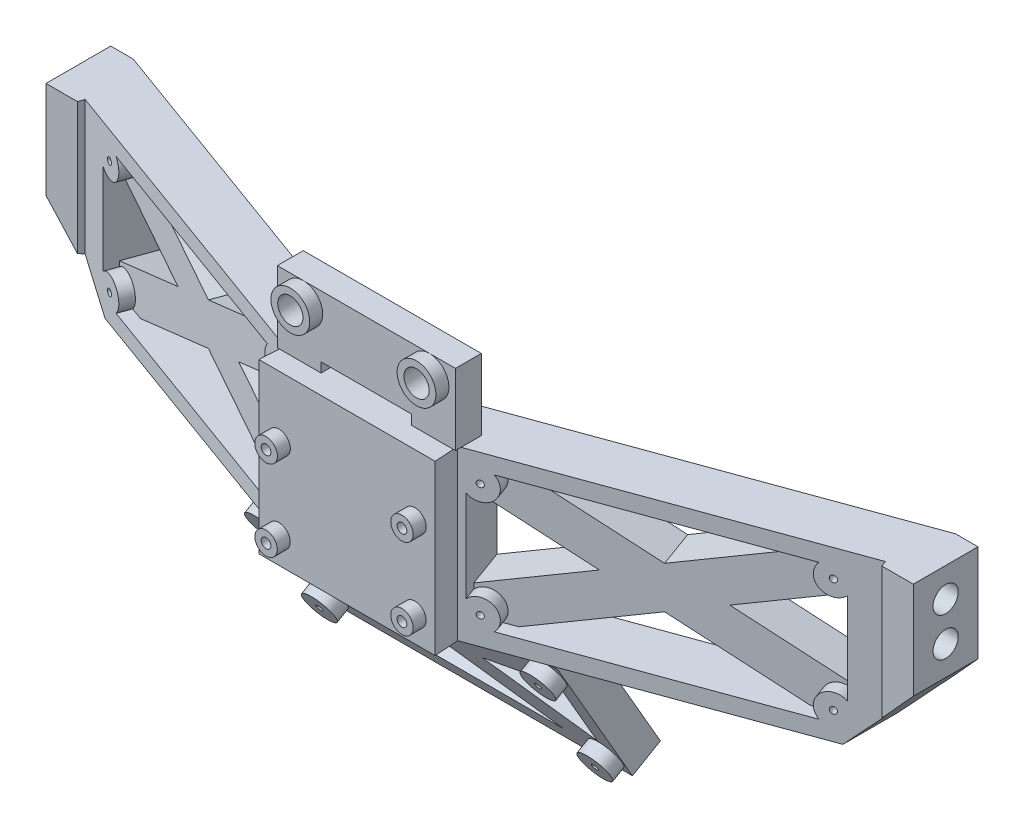
from build123d import *

# Parameters (mm, degrees)
SKETCH1_R                = 6
BOSS_EXTRUDE1_DEPTH      = 10
SKETCH3_R                = 0.75
BOSS_EXTRUDE2_DEPTH      = 15
BOSS_EXTRUDE2_DEPTH_BACK = 25
SKETCH5_W                = 30
SKETCH5_H                = 30.75
CUT_EXTRUDE1_DEPTH       = 2.5
SKETCH14_W               = 50
SKETCH14_H               = 25.4
BOSS_EXTRUDE5_DEPTH      = 38
SKETCH10_W               = 21
SKETCH10_H               = 46
CUT_EXTRUDE3_DEPTH       = 48
SKETCH16_W               = 48
SKETCH16_H               = 7.593294863
BOSS_EXTRUDE6_DEPTH      = 4
SKETCH5_2_W              = 30
SKETCH5_2_H              = 30.75
CUT_EXTRUDE6_DEPTH       = 4
CUT_EXTRUDE6_DEPTH_BACK  = 2.5
CUT_EXTRUDE4_DEPTH       = 40
SKETCH12_R               = 2.421843306
SKETCH12_R_2             = 0.5
BOSS_EXTRUDE4_DEPTH      = 5
SKETCH13_R               = 0.5
CUT_EXTRUDE5_DEPTH       = 15
SKETCH18_W               = 50
SKETCH18_H               = 34.502954744
BOSS_EXTRUDE7_DEPTH      = 2.5
CUT_EXTRUDE10_DEPTH      = 146.821613778
CUT_EXTRUDE12_DEPTH      = 129.953479984
CUT_EXTRUDE17_REACH      = 91.324
CUT_EXTRUDE20_DEPTH      = 116.734016398
SKETCH28_W               = 54.568484475
SKETCH28_H               = 26
CUT_EXTRUDE21_DEPTH      = 102.959878647
BOSS_EXTRUDE9_DEPTH      = 26
CUT_EXTRUDE22_DEPTH      = 100.460512237
BOSS_EXTRUDE11_DEPTH     = 7.992313589
CUT_EXTRUDE23_DEPTH      = 2
BOSS_EXTRUDE12_DEPTH     = 7.992313589
CUT_EXTRUDE24_DEPTH      = 2
SKETCH33_W               = 48
SKETCH33_H               = 23
BOSS_EXTRUDE13_DEPTH     = 5
SKETCH34_R               = 2.5
SKETCH34_R_2             = 0.5
BOSS_EXTRUDE14_DEPTH     = 2
SKETCH35_W               = 28.180148828
SKETCH35_H               = 26
SKETCH35_R               = 1.75
SKETCH35_R_2             = 1.73651938
CUT_EXTRUDE25_DEPTH      = 5
CUT_EXTRUDE27_DEPTH      = 96.41448763
SKETCH37_R               = 1.73651938
SKETCH37_R_2             = 0.75
SKETCH37_R_3             = 1.75
CUT_EXTRUDE28_DEPTH      = 3
BOSS_EXTRUDE15_REACH     = 115.866
BOSS_EXTRUDE16_DEPTH     = 1.474239
CUT_EXTRUDE29_DEPTH      = 86.045598256
CUT_EXTRUDE32_DEPTH      = 100.770044675
SKETCH45_W               = 0.142393119
SKETCH45_H               = 10
BOSS_EXTRUDE17_DEPTH     = 26
CUT_EXTRUDE37_DEPTH      = 100.356995224
BOSS_EXTRUDE18_START     = -5
BOSS_EXTRUDE18_DEPTH     = 4
BOSS_EXTRUDE19_START     = -5
SKETCH50_R               = 3
SKETCH50_R_2             = 1.95
BOSS_EXTRUDE19_DEPTH     = 2
SKETCH51_R               = 1.95
CUT_EXTRUDE39_DEPTH      = 109.019963433
SKETCH52_R               = 0.75
CUT_EXTRUDE40_DEPTH      = 109.019963433
SKETCH55_R               = 1.95
CUT_EXTRUDE42_DEPTH      = 10
CUT_EXTRUDE43_START      = -134
SKETCH55_2_R             = 1.95
CUT_EXTRUDE43_DEPTH      = 10
SKETCH56_W               = 27.512438804
SKETCH56_H               = 26
SKETCH56_R               = 1.73651938
SKETCH56_R_2             = 1.75
CUT_EXTRUDE44_DEPTH      = 2
SKETCH57_R               = 1.73651938
SKETCH57_R_2             = 1.75
CUT_EXTRUDE45_DEPTH      = 2
SKETCH58_W               = 27.512438804
SKETCH58_H               = 2.5
CUT_EXTRUDE46_DEPTH      = 107.622288946


with BuildPart() as part:
    # Sketch1 → Boss-Extrude1 (new body)
    with BuildSketch(Plane.XY):
        Polygon((-55, 98), (55, 98), (80, 78), (77.932657225, 6.656289752), (70, 0), (-70, 0), (-77.932657225, 6.656289752), (-80, 78), align=None)
        with Locations((-70, 28)):
            Circle(SKETCH1_R, mode=Mode.SUBTRACT)
        with Locations((70, 28)):
            Circle(SKETCH1_R, mode=Mode.SUBTRACT)
        with BuildLine():
            Line((-67.831737509, 72.367111823), (-50.790627288, 86))
            Line((-50.790627288, 86), (50.790627288, 86))
            Line((50.790627288, 86), (67.831737509, 72.367111823))
            Line((67.831737509, 72.367111823), (66.741852409, 34.755329324))
            ThreePointArc((66.741852409, 34.755329324), (62.503146817, 28.217238005), (66.356146477, 21.444671518))
            Line((66.356146477, 21.444671518), (66.09368314, 12.387098435))
            Line((66.09368314, 12.387098435), (65.632357189, 12))
            Line((65.632357189, 12), (-65.632357189, 12))
            Line((-65.632357189, 12), (-66.09368314, 12.387098435))
            Line((-66.09368314, 12.387098435), (-66.356146477, 21.444671518))
            ThreePointArc((-66.356146477, 21.444671518), (-62.503146817, 28.217238005), (-66.741852409, 34.755329324))
            Line((-66.741852409, 34.755329324), (-67.831737509, 72.367111823))
        make_face(mode=Mode.SUBTRACT)
    extrude(amount=BOSS_EXTRUDE1_DEPTH)



with BuildPart() as body_2:
    # Sketch3 → Boss-Extrude2 (new, two sides)
    with BuildSketch(Plane(origin=(0, 0, 0), x_dir=(-1, 0, 0), z_dir=(0, 0, -1))) as boss_extrude2_sk:
        Polygon((-13.5, 64.75), (-67.611014743, 64.75), (-66.857606881, 38.75), (-13.5, 38.75), (13.5, 38.75), (66.857606881, 38.75), (67.611014743, 64.75), (13.5, 64.75), align=None)
        with Locations((-10.5, 55.25)):
            Circle(SKETCH3_R, mode=Mode.SUBTRACT)
        with Locations((10.5, 55.25)):
            Circle(SKETCH3_R, mode=Mode.SUBTRACT)
        with Locations((10.5, 42.75)):
            Circle(SKETCH3_R, mode=Mode.SUBTRACT)
        with Locations((-10.5, 42.75)):
            Circle(SKETCH3_R, mode=Mode.SUBTRACT)
    extrude(amount=BOSS_EXTRUDE2_DEPTH)
    extrude(boss_extrude2_sk.sketch, amount=-BOSS_EXTRUDE2_DEPTH_BACK)

    # Sketch5 → Cut-Extrude1 (cut)
    with BuildSketch(Plane.XY.offset(25)):
        with Locations((0, 49.375)):
            Rectangle(SKETCH5_W, SKETCH5_H)
    extrude(amount=-CUT_EXTRUDE1_DEPTH, mode=Mode.SUBTRACT)


with BuildPart() as part_1:
    add(part.part)

    add(body_2.part)  # Boss-Extrude5 merges body 2
    # Sketch14 → Boss-Extrude5 (add)
    with BuildSketch(Plane(origin=(0, -1.317309472, 2.281646934), x_dir=(-1, 0, 0), z_dir=(0, -0.499999999999998, 0.8660254037844398))):
        with Locations((0, -26.058484397)):
            Rectangle(SKETCH14_W, SKETCH14_H)
    extrude(amount=-BOSS_EXTRUDE5_DEPTH)

    # Sketch10 → Cut-Extrude3 (cut)
    with BuildSketch(Plane(origin=(20.050116097, 0, 55.087241235), x_dir=(0, 1, 0), z_dir=(0.34202014332566943, 0, 0.9396926207859081))):
        with Locations((51.75, -32.544885729)):
            Rectangle(SKETCH10_W, SKETCH10_H)
    cut_extrude3 = extrude(amount=-CUT_EXTRUDE3_DEPTH, mode=Mode.SUBTRACT)

    # Sketch16 → Boss-Extrude6 (add)
    with BuildSketch(Plane(origin=(0, 33.5658321, 19.379242198), x_dir=(1, 0, 0), z_dir=(0, 0.8660254037844397, 0.499999999999998))):
        with Locations((-1, 1.162028489)):
            Rectangle(SKETCH16_W, SKETCH16_H)
    extrude(amount=BOSS_EXTRUDE6_DEPTH)

    # Sketch5_2 → Cut-Extrude6 (cut, two sides)
    with BuildSketch(Plane.XY.offset(25)) as cut_extrude6_sk:
        with Locations((0, 49.375)):
            Rectangle(SKETCH5_2_W, SKETCH5_2_H)
    extrude(amount=CUT_EXTRUDE6_DEPTH, mode=Mode.SUBTRACT)
    extrude(cut_extrude6_sk.sketch, amount=-CUT_EXTRUDE6_DEPTH_BACK, mode=Mode.SUBTRACT)

    # Mirror1: Cut-Extrude3 across plane
    add(cut_extrude3.mirror(Plane(origin=(0, 0, 0), x_dir=(0, 0, 1), z_dir=(1, 0, 0))), mode=Mode.SUBTRACT)

    # Sketch11 → Cut-Extrude4 (cut)
    with BuildSketch(Plane(origin=(0, 64.75, 0), x_dir=(1, 0, 0), z_dir=(0, 1, 0))):
        Polygon((-67.611014743, -10), (-15, -25), (15, -25), (67.611014743, -10), (67.611014743, -47.097490731), (-67.611014743, -47.097490731), align=None)
    extrude(amount=-CUT_EXTRUDE4_DEPTH, mode=Mode.SUBTRACT)

    # Sketch12 → Boss-Extrude4 (add)
    with BuildSketch(Plane(origin=(3.633149218, 0, 9.981995437), x_dir=(0.9396926207859082, 0, -0.34202014332566955), z_dir=(0.34202014332566955, 0, 0.9396926207859082))):
        with Locations((11.259885729, 60.54)):
            Circle(SKETCH12_R)
        with Locations((11.259885729, 60.54)):
            Circle(SKETCH12_R_2, mode=Mode.SUBTRACT)
        with Locations((53.829885729, 60.54)):
            Circle(SKETCH12_R)
        with Locations((53.829885729, 60.54)):
            Circle(SKETCH12_R_2, mode=Mode.SUBTRACT)
        with Locations((53.829885729, 42.96)):
            Circle(SKETCH12_R)
        with Locations((53.829885729, 42.96)):
            Circle(SKETCH12_R_2, mode=Mode.SUBTRACT)
        with Locations((11.259885729, 42.96)):
            Circle(SKETCH12_R)
        with Locations((11.259885729, 42.96)):
            Circle(SKETCH12_R_2, mode=Mode.SUBTRACT)
    boss_extrude4 = extrude(amount=BOSS_EXTRUDE4_DEPTH)

    # Sketch13 → Cut-Extrude5 (cut)
    with BuildSketch(Plane(origin=(3.633149218, 0, 9.981995437), x_dir=(0.9396926207859082, 0, -0.3420201433256695), z_dir=(0.3420201433256695, 0, 0.9396926207859082))):
        with Locations((53.829885729, 60.54)):
            Circle(SKETCH13_R)
        with Locations((53.829885729, 42.96)):
            Circle(SKETCH13_R)
        with Locations((11.259885729, 42.96)):
            Circle(SKETCH13_R)
        with Locations((11.259885729, 60.54)):
            Circle(SKETCH13_R)
    cut_extrude5 = extrude(amount=-CUT_EXTRUDE5_DEPTH, mode=Mode.SUBTRACT)

    # Mirror2: Boss-Extrude4, Cut-Extrude5 across plane
    add(boss_extrude4.mirror(Plane(origin=(0, 0, 0), x_dir=(0, 0, 1), z_dir=(1, 0, 0))))
    add(cut_extrude5.mirror(Plane(origin=(0, 0, 0), x_dir=(0, 0, 1), z_dir=(1, 0, 0))), mode=Mode.SUBTRACT)

    # Sketch18 → Boss-Extrude7 (add)
    with BuildSketch(Plane(origin=(0, 11.568786844, 6.679242198), x_dir=(1, 0, 0), z_dir=(0, -0.8660254037844397, -0.499999999999998))):
        with Locations((0, -18.113903685)):
            Rectangle(SKETCH18_W, SKETCH18_H)
    extrude(amount=BOSS_EXTRUDE7_DEPTH)

    # Sketch20 → Cut-Extrude10 (cut, through all)
    with BuildSketch(Plane(origin=(25, 0, 0), x_dir=(0, 0, -1), z_dir=(1, 0, 0))):
        Polygon((15, 44.75), (15, 38.75), (8.051233494, 17.186679604), (32.373818215, 22.723551455), (24.867864478, 46.825237766), align=None)
    extrude(amount=-CUT_EXTRUDE10_DEPTH, mode=Mode.SUBTRACT)

    # Sketch21 → Cut-Extrude12 (cut, through all)
    with BuildSketch(Plane.XY.offset(10)):
        Polygon((80, 78), (55, 98), (-55, 98), (-80, 78), (-77.932657225, 6.656289752), (-70, 0), (70, 0), (77.932657225, 6.656289752), align=None)
        with BuildLine():
            Line((-67.611014743, 64.75), (-66.857606881, 38.75))
            Line((-66.857606881, 38.75), (-66.741852409, 34.755329324))
            ThreePointArc((-66.741852409, 34.755329324), (-62.503146817, 28.217238005), (-66.356146477, 21.444671518))
            Line((-66.356146477, 21.444671518), (-66.09368314, 12.387098435))
            Line((-66.09368314, 12.387098435), (-65.632357189, 12))
            Line((-65.632357189, 12), (65.632357189, 12))
            Line((65.632357189, 12), (66.09368314, 12.387098435))
            Line((66.09368314, 12.387098435), (66.356146477, 21.444671518))
            ThreePointArc((66.356146477, 21.444671518), (62.503146817, 28.217238005), (66.741852409, 34.755329324))
            Line((66.741852409, 34.755329324), (66.857606881, 38.75))
            Line((66.857606881, 38.75), (67.611014743, 64.75))
            Line((67.611014743, 64.75), (67.831737509, 72.367111823))
            Line((67.831737509, 72.367111823), (50.790627288, 86))
            Line((50.790627288, 86), (-50.790627288, 86))
            Line((-50.790627288, 86), (-67.831737509, 72.367111823))
            Line((-67.831737509, 72.367111823), (-67.611014743, 64.75))
        make_face(mode=Mode.SUBTRACT)
    extrude(amount=-CUT_EXTRUDE12_DEPTH, mode=Mode.SUBTRACT)

    # Sketch26 → Cut-Extrude17 (cut, up to next)
    with BuildSketch(Plane(origin=(0, 64.75, 0), x_dir=(1, 0, 0), z_dir=(0, 1, 0)), mode=Mode.PRIVATE) as cut_extrude17_sk1:
        Polygon((0, -8.12), (-103.081644476, 29.398650288), (100.191184864, 28.346609026), align=None)
    cut_extrude17_tool1 = extrude(cut_extrude17_sk1.sketch, amount=-CUT_EXTRUDE17_REACH, mode=Mode.PRIVATE) & part_1.part
    add(cut_extrude17_tool1.solids().sort_by_distance((-0.963487, 64.75, -16.541753))[0], mode=Mode.SUBTRACT)

    # Sketch27 → Cut-Extrude20 (cut, through all)
    with BuildSketch(Plane.ZY.offset(25)):
        Polygon((-0.979255857, 38.75), (29.245394975, 38.75), (32.788291765, 8.744578546), (-21.074810998, 9.132082883), align=None)
    extrude(amount=-CUT_EXTRUDE20_DEPTH, mode=Mode.SUBTRACT)

    # Sketch28 → Cut-Extrude21 (cut, through all)
    with BuildSketch(Plane(origin=(-5.343249934, 0, 14.680458541), x_dir=(0.9396926207859081, 0, 0.34202014332566955), z_dir=(-0.34202014332566955, 0, 0.9396926207859082))):
        with Locations((-32.829127967, 51.75)):
            Rectangle(SKETCH28_W, SKETCH28_H)
    cut_extrude21 = extrude(amount=CUT_EXTRUDE21_DEPTH, mode=Mode.SUBTRACT)

    # Mirror3: Cut-Extrude21 across plane
    add(cut_extrude21.mirror(Plane(origin=(0, 0, 0), x_dir=(0, 0, 1), z_dir=(1, 0, 0))), mode=Mode.SUBTRACT)

    # Sketch29 → Boss-Extrude9 (add)
    with BuildSketch(Plane(origin=(0, 64.75, 0), x_dir=(1, 0, 0), z_dir=(0, 1, 0))):
        Polygon((-14.090074414, -22.5), (-13.372815999, -11.7579355), (-10.553738137, -12.78399593), align=None)
        Polygon((13.372815999, -11.7579355), (10.553738137, -12.78399593), (14.090074414, -22.5), align=None)
    extrude(amount=-BOSS_EXTRUDE9_DEPTH)

    # Sketch31 → Cut-Extrude22 (cut, through all)
    with BuildSketch(Plane(origin=(3.633149218, 0, 9.981995437), x_dir=(0.9396926207859082, 0, -0.3420201433256695), z_dir=(0.3420201433256695, 0, 0.9396926207859082))):
        with BuildLine():
            Line((9.544885729, 58.83), (9.544885729, 44.67))
            ThreePointArc((9.544885729, 44.67), (12.969885729, 44.675), (12.974885729, 41.25))
            Line((12.974885729, 41.25), (52.114885729, 41.25))
            ThreePointArc((52.114885729, 41.25), (52.119885729, 44.675), (55.544885729, 44.67))
            Line((55.544885729, 44.67), (55.544885729, 58.83))
            ThreePointArc((55.544885729, 58.83), (52.119885729, 58.825), (52.114885729, 62.25))
            Line((52.114885729, 62.25), (12.974885729, 62.25))
            ThreePointArc((12.974885729, 62.25), (12.969885729, 58.825), (9.544885729, 58.83))
        make_face()
    cut_extrude22 = extrude(amount=-CUT_EXTRUDE22_DEPTH, mode=Mode.SUBTRACT)

    # Mirror4: Cut-Extrude22 across plane
    add(cut_extrude22.mirror(Plane(origin=(0, 0, 0), x_dir=(0, 0, 1), z_dir=(1, 0, 0))), mode=Mode.SUBTRACT)

    # Sketch30 → Boss-Extrude11 (add)
    with BuildSketch(Plane(origin=(-5.343249934, 0, 14.680458541), x_dir=(0.9396926207859081, 0, 0.34202014332566955), z_dir=(-0.34202014332566955, 0, 0.9396926207859082))):
        with BuildLine():
            Line((-55.544885729, 58.002491012), (-40.404468073, 51.75))
            Line((-40.404468073, 51.75), (-55.544885729, 45.497508988))
            Line((-55.544885729, 45.497508988), (-55.544885729, 44.67))
            ThreePointArc((-55.544885729, 44.67), (-52.119885729, 44.675), (-52.114885729, 41.25))
            Line((-52.114885729, 41.25), (-50.111071302, 41.25))
            Line((-50.111071302, 41.25), (-32.544885729, 48.504252816))
            Line((-32.544885729, 48.504252816), (-14.978700155, 41.25))
            Line((-14.978700155, 41.25), (-12.974885729, 41.25))
            ThreePointArc((-12.974885729, 41.25), (-12.969885729, 44.675), (-9.544885729, 44.67))
            Line((-9.544885729, 44.67), (-9.544885729, 45.497508988))
            Line((-9.544885729, 45.497508988), (-24.685303384, 51.75))
            Line((-24.685303384, 51.75), (-9.544885729, 58.002491012))
            Line((-9.544885729, 58.002491012), (-9.544885729, 58.83))
            ThreePointArc((-9.544885729, 58.83), (-12.969885729, 58.825), (-12.974885729, 62.25))
            Line((-12.974885729, 62.25), (-14.978700155, 62.25))
            Line((-14.978700155, 62.25), (-32.544885729, 54.995747184))
            Line((-32.544885729, 54.995747184), (-50.111071302, 62.25))
            Line((-50.111071302, 62.25), (-52.114885729, 62.25))
            ThreePointArc((-52.114885729, 62.25), (-52.119885729, 58.825), (-55.544885729, 58.83))
            Line((-55.544885729, 58.83), (-55.544885729, 58.002491012))
        make_face()
    extrude(amount=-BOSS_EXTRUDE11_DEPTH)

    # Sketch30_2 → Cut-Extrude23 (cut)
    with BuildSketch(Plane(origin=(-5.343249934, 0, 14.680458541), x_dir=(0.9396926207859081, 0, 0.34202014332566955), z_dir=(-0.34202014332566955, 0, 0.9396926207859082))):
        with BuildLine():
            Line((-55.544885729, 58.002491012), (-40.404468073, 51.75))
            Line((-40.404468073, 51.75), (-55.544885729, 45.497508988))
            Line((-55.544885729, 45.497508988), (-55.544885729, 44.67))
            ThreePointArc((-55.544885729, 44.67), (-52.119885729, 44.675), (-52.114885729, 41.25))
            Line((-52.114885729, 41.25), (-50.111071302, 41.25))
            Line((-50.111071302, 41.25), (-32.544885729, 48.504252816))
            Line((-32.544885729, 48.504252816), (-14.978700155, 41.25))
            Line((-14.978700155, 41.25), (-12.974885729, 41.25))
            ThreePointArc((-12.974885729, 41.25), (-12.969885729, 44.675), (-9.544885729, 44.67))
            Line((-9.544885729, 44.67), (-9.544885729, 45.497508988))
            Line((-9.544885729, 45.497508988), (-24.685303384, 51.75))
            Line((-24.685303384, 51.75), (-9.544885729, 58.002491012))
            Line((-9.544885729, 58.002491012), (-9.544885729, 58.83))
            ThreePointArc((-9.544885729, 58.83), (-12.969885729, 58.825), (-12.974885729, 62.25))
            Line((-12.974885729, 62.25), (-14.978700155, 62.25))
            Line((-14.978700155, 62.25), (-32.544885729, 54.995747184))
            Line((-32.544885729, 54.995747184), (-50.111071302, 62.25))
            Line((-50.111071302, 62.25), (-52.114885729, 62.25))
            ThreePointArc((-52.114885729, 62.25), (-52.119885729, 58.825), (-55.544885729, 58.83))
            Line((-55.544885729, 58.83), (-55.544885729, 58.002491012))
        make_face()
    extrude(amount=-CUT_EXTRUDE23_DEPTH, mode=Mode.SUBTRACT)

    # Sketch32 → Boss-Extrude12 (add)
    with BuildSketch(Plane(origin=(5.343249934, 0, 14.680458541), x_dir=(0.9396926207859081, 0, -0.34202014332566955), z_dir=(0.34202014332566955, 0, 0.9396926207859082))):
        with BuildLine():
            Line((32.544885729, 54.995747184), (14.978700155, 62.25))
            Line((14.978700155, 62.25), (12.974885729, 62.25))
            ThreePointArc((12.974885729, 62.25), (12.969885729, 58.825), (9.544885729, 58.83))
            Line((9.544885729, 58.83), (9.544885729, 58.002491012))
            Line((9.544885729, 58.002491012), (24.685303384, 51.75))
            Line((24.685303384, 51.75), (32.544885729, 54.995747184))
        make_face()
        with BuildLine():
            Line((50.111071302, 62.25), (32.544885729, 54.995747184))
            Line((32.544885729, 54.995747184), (40.404468073, 51.75))
            Line((40.404468073, 51.75), (55.544885729, 58.002491012))
            Line((55.544885729, 58.002491012), (55.544885729, 58.83))
            ThreePointArc((55.544885729, 58.83), (52.119885729, 58.825), (52.114885729, 62.25))
            Line((52.114885729, 62.25), (50.111071302, 62.25))
        make_face()
        Polygon((40.404468073, 51.75), (32.544885729, 54.995747184), (24.685303384, 51.75), (32.544885729, 48.504252816), align=None)
        with BuildLine():
            Line((32.544885729, 48.504252816), (24.685303384, 51.75))
            Line((24.685303384, 51.75), (9.544885729, 45.497508988))
            Line((9.544885729, 45.497508988), (9.544885729, 44.67))
            ThreePointArc((9.544885729, 44.67), (12.969885729, 44.675), (12.974885729, 41.25))
            Line((12.974885729, 41.25), (14.978700155, 41.25))
            Line((14.978700155, 41.25), (32.544885729, 48.504252816))
        make_face()
        with BuildLine():
            Line((55.544885729, 45.497508988), (40.404468073, 51.75))
            Line((40.404468073, 51.75), (32.544885729, 48.504252816))
            Line((32.544885729, 48.504252816), (50.111071302, 41.25))
            Line((50.111071302, 41.25), (52.114885729, 41.25))
            ThreePointArc((52.114885729, 41.25), (52.119885729, 44.675), (55.544885729, 44.67))
            Line((55.544885729, 44.67), (55.544885729, 45.497508988))
        make_face()
    extrude(amount=-BOSS_EXTRUDE12_DEPTH)

    # Sketch32_4 → Cut-Extrude24 (cut)
    with BuildSketch(Plane(origin=(5.343249934, 0, 14.680458541), x_dir=(0.9396926207859081, 0, -0.34202014332566955), z_dir=(0.34202014332566955, 0, 0.9396926207859082))):
        with BuildLine():
            Line((32.544885729, 54.995747184), (14.978700155, 62.25))
            Line((14.978700155, 62.25), (12.974885729, 62.25))
            ThreePointArc((12.974885729, 62.25), (12.969885729, 58.825), (9.544885729, 58.83))
            Line((9.544885729, 58.83), (9.544885729, 58.002491012))
            Line((9.544885729, 58.002491012), (24.685303384, 51.75))
            Line((24.685303384, 51.75), (32.544885729, 54.995747184))
        make_face()
        Polygon((40.404468073, 51.75), (32.544885729, 54.995747184), (24.685303384, 51.75), (32.544885729, 48.504252816), align=None)
        with BuildLine():
            Line((50.111071302, 62.25), (32.544885729, 54.995747184))
            Line((32.544885729, 54.995747184), (40.404468073, 51.75))
            Line((40.404468073, 51.75), (55.544885729, 58.002491012))
            Line((55.544885729, 58.002491012), (55.544885729, 58.83))
            ThreePointArc((55.544885729, 58.83), (52.119885729, 58.825), (52.114885729, 62.25))
            Line((52.114885729, 62.25), (50.111071302, 62.25))
        make_face()
        with BuildLine():
            Line((55.544885729, 45.497508988), (40.404468073, 51.75))
            Line((40.404468073, 51.75), (32.544885729, 48.504252816))
            Line((32.544885729, 48.504252816), (50.111071302, 41.25))
            Line((50.111071302, 41.25), (52.114885729, 41.25))
            ThreePointArc((52.114885729, 41.25), (52.119885729, 44.675), (55.544885729, 44.67))
            Line((55.544885729, 44.67), (55.544885729, 45.497508988))
        make_face()
        with BuildLine():
            Line((32.544885729, 48.504252816), (24.685303384, 51.75))
            Line((24.685303384, 51.75), (9.544885729, 45.497508988))
            Line((9.544885729, 45.497508988), (9.544885729, 44.67))
            ThreePointArc((9.544885729, 44.67), (12.969885729, 44.675), (12.974885729, 41.25))
            Line((12.974885729, 41.25), (14.978700155, 41.25))
            Line((14.978700155, 41.25), (32.544885729, 48.504252816))
        make_face()
    extrude(amount=-CUT_EXTRUDE24_DEPTH, mode=Mode.SUBTRACT)

    # Sketch33 → Boss-Extrude13 (add)
    with BuildSketch(Plane(origin=(0, 8.944714207, -15.492699466), x_dir=(1, 0, 0), z_dir=(0, -0.5000000000000101, 0.8660254037844328))):
        with Locations((0, 24.618484397)):
            Rectangle(SKETCH33_W, SKETCH33_H)
    extrude(amount=BOSS_EXTRUDE13_DEPTH)

    # Sketch34 → Boss-Extrude14 (add)
    with BuildSketch(Plane(origin=(0, 6.444714207, -11.162572448), x_dir=(1, 0, 0), z_dir=(0, -0.5000000000000102, 0.8660254037844327))):
        with Locations(Location((-21.285, 33.408484397, 0), (0, 0, 90))):
            Circle(SKETCH34_R)
        with Locations(Location((-21.285, 33.408484397, 0), (0, 0, 270))):
            Circle(SKETCH34_R_2, mode=Mode.SUBTRACT)
        with Locations(Location((-21.285, 15.828484397, 0), (0, 0, 90))):
            Circle(SKETCH34_R)
        with Locations(Location((-21.285, 15.828484397, 0), (0, 0, 270))):
            Circle(SKETCH34_R_2, mode=Mode.SUBTRACT)
        with Locations(Location((21.285, 15.828484397, 0), (0, 0, 90))):
            Circle(SKETCH34_R)
        with Locations(Location((21.285, 15.828484397, 0), (0, 0, 270))):
            Circle(SKETCH34_R_2, mode=Mode.SUBTRACT)
        with Locations(Location((21.285, 33.408484397, 0), (0, 0, 90))):
            Circle(SKETCH34_R)
        with Locations(Location((21.285, 33.408484397, 0), (0, 0, 270))):
            Circle(SKETCH34_R_2, mode=Mode.SUBTRACT)
    extrude(amount=BOSS_EXTRUDE14_DEPTH)

    # Sketch35 → Cut-Extrude25 (cut)
    with BuildSketch(Plane.XY.offset(22.5)):
        with Locations((0, 51.75)):
            Rectangle(SKETCH35_W, SKETCH35_H)
        with Locations((-10.5, 55.25)):
            Circle(SKETCH35_R, mode=Mode.SUBTRACT)
        with Locations((10.5, 55.25)):
            Circle(SKETCH35_R_2, mode=Mode.SUBTRACT)
        with Locations((10.5, 42.75)):
            Circle(SKETCH35_R_2, mode=Mode.SUBTRACT)
        with Locations((-10.5, 42.75)):
            Circle(SKETCH35_R_2, mode=Mode.SUBTRACT)
    extrude(amount=-CUT_EXTRUDE25_DEPTH, mode=Mode.SUBTRACT)

    # Sketch36 → Cut-Extrude27 (cut, through all)
    with BuildSketch(Plane(origin=(0, 6.444714207, -11.162572448), x_dir=(1, 0, 0), z_dir=(0, -0.5000000000000103, 0.8660254037844328))):
        Polygon((-14.735348046, 33.408484397), (0, 27.323273717), (14.735348046, 33.408484397), align=None)
        Polygon((14.735348046, 15.828484397), (0, 21.913695077), (-14.735348046, 15.828484397), align=None)
        Polygon((-21.285, 18.533273717), (-6.549651954, 24.618484397), (-21.285, 30.703695077), align=None)
        Polygon((21.285, 30.703695077), (6.549651954, 24.618484397), (21.285, 18.533273717), align=None)
    extrude(amount=-CUT_EXTRUDE27_DEPTH, mode=Mode.SUBTRACT)

    # Sketch37 → Cut-Extrude28 (cut)
    with BuildSketch(Plane.XY.offset(22.5)):
        with Locations((10.5, 42.75)):
            Circle(SKETCH37_R)
        with Locations(Location((10.5, 42.75, 0), (0, 0, 230.377503167))):
            Circle(SKETCH37_R_2, mode=Mode.SUBTRACT)
        with Locations((10.5, 55.25)):
            Circle(SKETCH37_R)
        with Locations((10.5, 55.25)):
            Circle(SKETCH37_R_2, mode=Mode.SUBTRACT)
        with Locations((-10.5, 42.75)):
            Circle(SKETCH37_R)
        with Locations(Location((-10.5, 42.75, 0), (0, 0, 206.642765316))):
            Circle(SKETCH37_R_2, mode=Mode.SUBTRACT)
        with Locations((-10.5, 55.25)):
            Circle(SKETCH37_R_3)
        with Locations(Location((-10.5, 55.25, 0), (0, 0, 180))):
            Circle(SKETCH37_R_2, mode=Mode.SUBTRACT)
    extrude(amount=-CUT_EXTRUDE28_DEPTH, mode=Mode.SUBTRACT)

    # Boss-Extrude15: up to this face of the body (flat: up to its plane)
    boss_extrude15_end = Plane(part_1.part.faces().sort_by_distance((24, 28.786799743, -1.111031094))[0])
    # Sketch38 → Boss-Extrude15 (add, up to the picked face)
    with BuildSketch(Plane.ZY.offset(24), mode=Mode.PRIVATE) as boss_extrude15_sk1:
        Polygon((5.12, 38.75), (6.896669751, 37.724239241), (7.930028914, 38.75), align=None)
    boss_extrude15_tool1 = split(extrude(boss_extrude15_sk1.sketch, amount=-BOSS_EXTRUDE15_REACH, mode=Mode.PRIVATE), bisect_by=boss_extrude15_end, keep=Keep.BOTH, mode=Mode.PRIVATE)
    add(boss_extrude15_tool1.solids().sort_by(Axis((-24, 38.40808, 6.6489), (1, 0, 0)))[0])

    # Sketch39 → Boss-Extrude16 (add)
    with BuildSketch(Plane(origin=(0, 38.75, 0), x_dir=(1, 0, 0), z_dir=(0, 1, 0))):
        Polygon((0, -8.12), (-15.257998444, -2.566542732), (15.257998444, -2.566542732), align=None)
    extrude(amount=BOSS_EXTRUDE16_DEPTH)

    # Sketch40 → Cut-Extrude29 (cut, through all)
    with BuildSketch(Plane(origin=(0, 64.75, 0), x_dir=(1, 0, 0), z_dir=(0, 1, 0))):
        Polygon((-67.611014743, -10), (-67.611014743, 5), (-62.151461229, 5), align=None)
        Polygon((67.611014743, -10), (67.611014743, 5), (62.151461229, 5), align=None)
    extrude(amount=-CUT_EXTRUDE29_DEPTH, mode=Mode.SUBTRACT)

    # Sketch43 → Cut-Extrude32 (cut, through all)
    with BuildSketch(Plane(origin=(0, 0, -15), x_dir=(-1, 0, 0), z_dir=(0, 0, -1))):
        Polygon((-66.857606881, 38.75), (-66.857606881, 64.75), (-67.611014743, 64.75), align=None)
        Polygon((66.857606881, 38.75), (66.857606881, 64.75), (67.611014743, 64.75), align=None)
    extrude(amount=-CUT_EXTRUDE32_DEPTH, mode=Mode.SUBTRACT)

    # Sketch45 → Boss-Extrude17 (add)
    with BuildSketch(Plane(origin=(0, 64.75, 0), x_dir=(1, 0, 0), z_dir=(0, 1, 0))):
        with Locations((-66.928803441, 10)):
            Rectangle(SKETCH45_W, SKETCH45_H)
        with Locations((66.928803441, 10)):
            Rectangle(SKETCH45_W, SKETCH45_H)
    extrude(amount=-BOSS_EXTRUDE17_DEPTH)

    # Sketch47 → Cut-Extrude37 (cut, through all)
    with BuildSketch(Plane(origin=(0, 0, -15), x_dir=(-1, 0, 0), z_dir=(0, 0, -1))):
        Polygon((57, 38.75), (67, 49.75), (67, 38.75), align=None)
        Polygon((-67, 38.75), (-57, 38.75), (-67, 49.75), align=None)
    extrude(amount=-CUT_EXTRUDE37_DEPTH, mode=Mode.SUBTRACT)

    # Sketch48 → Boss-Extrude18 (add)
    with BuildSketch(Plane.XY.offset(17.5).offset(BOSS_EXTRUDE18_START)):
        Polygon((-13.756219402, 64.75), (-7, 64.75), (-7, 66.25), (7, 66.25), (7, 64.75), (13.756219402, 64.75), (13.756219402, 78.25), (-13.756219402, 78.25), align=None)
    extrude(amount=-BOSS_EXTRUDE18_DEPTH)

    # Sketch50 → Boss-Extrude19 (add)
    with BuildSketch(Plane.XY.offset(17.5).offset(BOSS_EXTRUDE19_START)):
        with Locations(Location((9.75, 72.75, 0), (0, 0, 180))):
            Circle(SKETCH50_R)
        with Locations(Location((9.75, 72.75, 0), (0, 0, 180))):
            Circle(SKETCH50_R_2, mode=Mode.SUBTRACT)
        with Locations(Location((-9.75, 72.75, 0), (0, 0, 180))):
            Circle(SKETCH50_R)
        with Locations(Location((-9.75, 72.75, 0), (0, 0, 180))):
            Circle(SKETCH50_R_2, mode=Mode.SUBTRACT)
    extrude(amount=BOSS_EXTRUDE19_DEPTH)

    # Sketch51 → Cut-Extrude39 (cut, through all)
    with BuildSketch(Plane.XY.offset(17.5)):
        with Locations(Location((9.75, 72.75, 0), (0, 0, 180))):
            Circle(SKETCH51_R)
        with Locations(Location((-9.75, 72.75, 0), (0, 0, 180))):
            Circle(SKETCH51_R)
    extrude(amount=-CUT_EXTRUDE39_DEPTH, mode=Mode.SUBTRACT)

    # Sketch52 → Cut-Extrude40 (cut, through all)
    with BuildSketch(Plane.XY.offset(17.5)):
        with Locations(Location((-10.5, 55.25, 0), (0, 0, 180))):
            Circle(SKETCH52_R)
        with Locations((10.5, 55.25)):
            Circle(SKETCH52_R)
        with Locations((10.5, 42.75)):
            Circle(SKETCH52_R)
        with Locations(Location((-10.5, 42.75, 0), (0, 0, 180))):
            Circle(SKETCH52_R)
    extrude(amount=-CUT_EXTRUDE40_DEPTH, mode=Mode.SUBTRACT)

    # Sketch55 → Cut-Extrude42 (cut)
    with BuildSketch(Plane.ZY.offset(67)):
        with Locations((-10, 60.25)):
            Circle(SKETCH55_R)
        with Locations((-10, 54.25)):
            Circle(SKETCH55_R)
    extrude(amount=-CUT_EXTRUDE42_DEPTH, mode=Mode.SUBTRACT)

    # Sketch55_2 → Cut-Extrude43 (cut)
    with BuildSketch(Plane.ZY.offset(67).offset(CUT_EXTRUDE43_START)):
        with Locations((-10, 60.25)):
            Circle(SKETCH55_2_R)
        with Locations((-10, 54.25)):
            Circle(SKETCH55_2_R)
    extrude(amount=CUT_EXTRUDE43_DEPTH, mode=Mode.SUBTRACT)

    # Sketch56 → Cut-Extrude44 (cut)
    with BuildSketch(Plane.XY.offset(17.5)):
        with Locations((0, 51.75)):
            Rectangle(SKETCH56_W, SKETCH56_H)
        with Locations((-10.5, 42.75)):
            Circle(SKETCH56_R, mode=Mode.SUBTRACT)
        with Locations((10.5, 42.75)):
            Circle(SKETCH56_R, mode=Mode.SUBTRACT)
        with Locations((10.5, 55.25)):
            Circle(SKETCH56_R, mode=Mode.SUBTRACT)
        with Locations((-10.5, 55.25)):
            Circle(SKETCH56_R_2, mode=Mode.SUBTRACT)
    extrude(amount=-CUT_EXTRUDE44_DEPTH, mode=Mode.SUBTRACT)

    # Sketch57 → Cut-Extrude45 (cut)
    with BuildSketch(Plane.XY.offset(19.5)):
        with Locations((10.5, 55.25)):
            Circle(SKETCH57_R)
        with Locations((10.5, 42.75)):
            Circle(SKETCH57_R)
        with Locations((-10.5, 42.75)):
            Circle(SKETCH57_R)
        with Locations((-10.5, 55.25)):
            Circle(SKETCH57_R_2)
    extrude(amount=-CUT_EXTRUDE45_DEPTH, mode=Mode.SUBTRACT)

    # Sketch58 → Cut-Extrude46 (cut, through all)
    with BuildSketch(Plane.XY.offset(12.5)):
        with Locations((0, 77)):
            Rectangle(SKETCH58_W, SKETCH58_H)
    extrude(amount=-CUT_EXTRUDE46_DEPTH, mode=Mode.SUBTRACT)


solid = part_1.part
